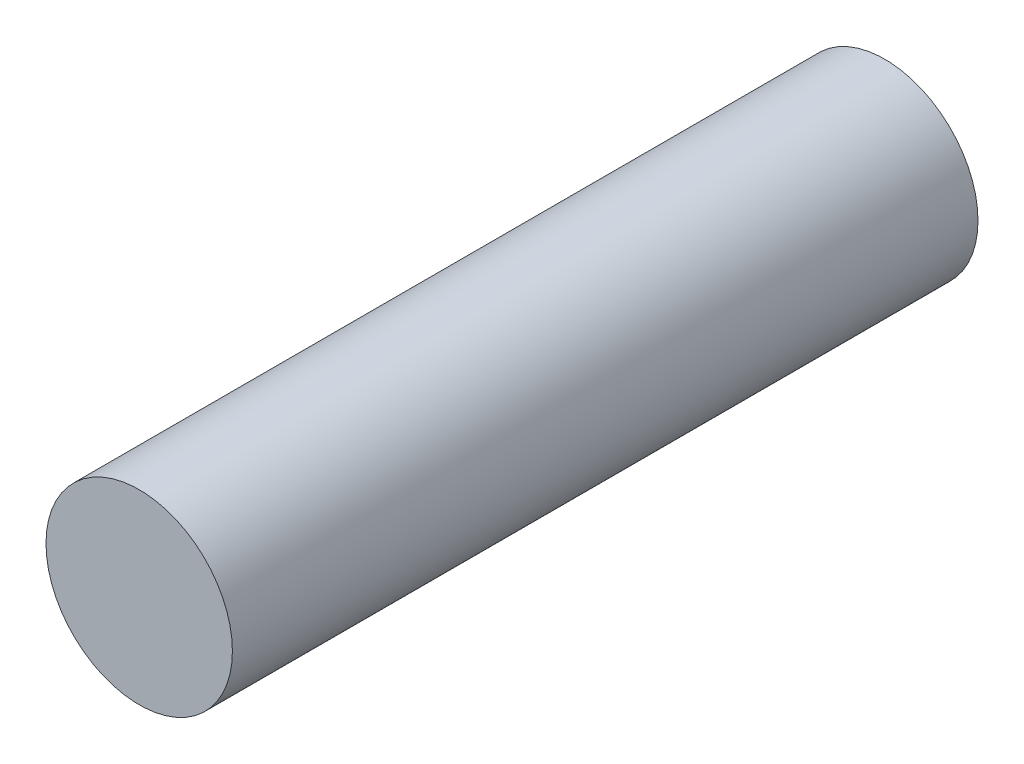
from build123d import *

# Parameters (mm, degrees)
SKETCH1_R           = 6.35
BOSS_EXTRUDE1_DEPTH = 50.8
SKETCH2_R           = 1.5875
CUT_EXTRUDE1_DEPTH  = 12.7


with BuildPart() as part:
    # Sketch1 → Boss-Extrude1 (new body)
    with BuildSketch(Plane.XY):
        Circle(SKETCH1_R)
    extrude(amount=BOSS_EXTRUDE1_DEPTH)

    # Sketch2 → Cut-Extrude1 (cut)
    with BuildSketch(Plane(origin=(0, 0, 0), x_dir=(-1, 0, 0), z_dir=(0, 0, -1))):
        Circle(SKETCH2_R)
    extrude(amount=-CUT_EXTRUDE1_DEPTH, mode=Mode.SUBTRACT)


solid = part.part
